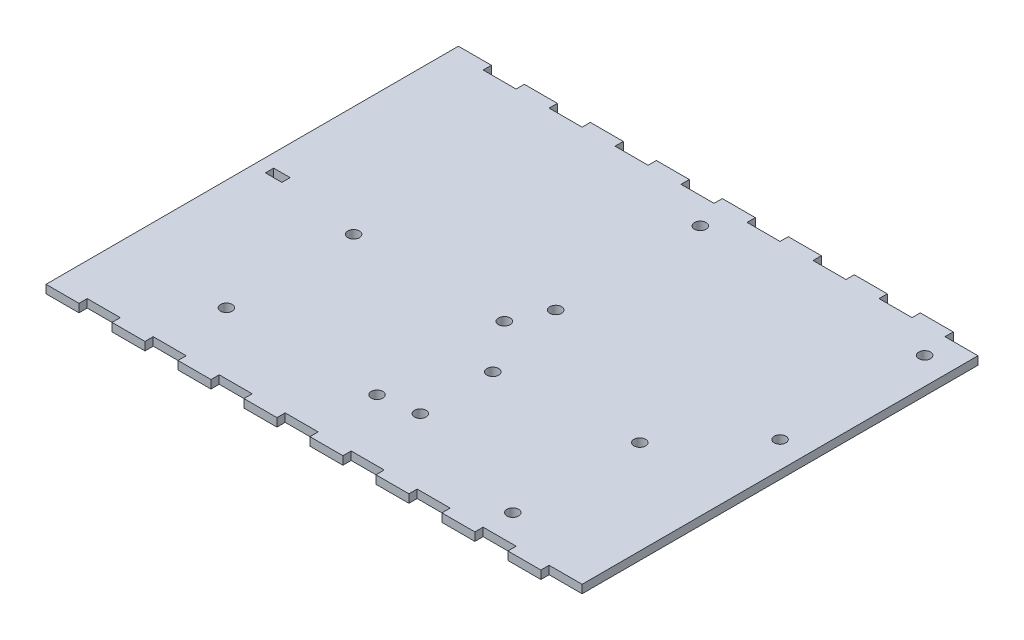
from build123d import *

# Parameters (mm, degrees)
SKETCH1_W               = 203.2
SKETCH1_H               = 152.4
BOSS_EXTRUDE1_DEPTH     = 3.175
SKETCH2_W               = 12.7
SKETCH2_H               = 3.175
BOSS_EXTRUDE2_DEPTH     = 3.175
BOSS_EXTRUDE2_2_DEPTH   = 3.175
BOSS_EXTRUDE2_3_DEPTH   = 3.175
BOSS_EXTRUDE2_4_DEPTH   = 3.175
BOSS_EXTRUDE2_5_DEPTH   = 3.175
BOSS_EXTRUDE2_6_DEPTH   = 3.175
BOSS_EXTRUDE2_7_DEPTH   = 3.175
BOSS_EXTRUDE2_8_DEPTH   = 3.175
BOSS_EXTRUDE2_9_DEPTH   = 3.175
BOSS_EXTRUDE2_10_DEPTH  = 3.175
BOSS_EXTRUDE2_11_DEPTH  = 3.175
BOSS_EXTRUDE2_12_DEPTH  = 3.175
BOSS_EXTRUDE2_13_DEPTH  = 3.175
BOSS_EXTRUDE2_14_DEPTH  = 3.175
BOSS_EXTRUDE2_15_DEPTH  = 3.175
BOSS_EXTRUDE2_16_DEPTH  = 3.175
SKETCH4_R               = 2.249999945
CUT_EXTRUDE1_DEPTH      = 239.445094336
SKETCH5_R               = 2.249999945
CUT_EXTRUDE2_DEPTH      = 411.418751092
CUT_EXTRUDE3_DEPTH      = 181.542007906
CUT_EXTRUDE3_DEPTH_BACK = 181.542007906
SKETCH10_R              = 2.249999945
SKETCH11_W              = 6.35
SKETCH11_H              = 3.175
CUT_EXTRUDE4_DEPTH      = 256.93729945


with BuildPart() as part:
    # Sketch1 → Boss-Extrude1 (new body)
    with BuildSketch(Plane(origin=(0, 0, 0), x_dir=(1, 0, 0), z_dir=(0, 1, 0))):
        with Locations((101.6, 76.2)):
            Rectangle(SKETCH1_W, SKETCH1_H)
    extrude(amount=BOSS_EXTRUDE1_DEPTH)

    # Sketch4 → Cut-Extrude1 (cut, through all)
    with BuildSketch(Plane(origin=(163.318517222, 3.175, 18.128898402), x_dir=(-1, 0, 0), z_dir=(0, 1, 0))):
        with Locations((62.768517222, -41.828898402)):
            Circle(SKETCH4_R)
        with Locations((62.768517222, -90.828898402)):
            Circle(SKETCH4_R)
        with Locations((120.768517222, -90.828898402)):
            Circle(SKETCH4_R)
        with Locations((120.768517222, -41.828898402)):
            Circle(SKETCH4_R)
    extrude(amount=-CUT_EXTRUDE1_DEPTH, mode=Mode.SUBTRACT)

    # Sketch5 → Cut-Extrude2 (cut, through all)
    with BuildSketch(Plane(origin=(307.482010873, 3.175, -268.648993813), x_dir=(-1, 0, 0), z_dir=(0, 1, 0))):
        with Locations((140.407118473, 210.304081528)):
            Circle(SKETCH5_R)
        with Locations((141.507118473, 258.104081528)):
            Circle(SKETCH5_R)
        with Locations((192.307118473, 215.004081528)):
            Circle(SKETCH5_R)
        with Locations((192.307118473, 242.904081528)):
            Circle(SKETCH5_R)
    extrude(amount=-CUT_EXTRUDE2_DEPTH, mode=Mode.SUBTRACT)

    # Sketch10 → Cut-Extrude3 (cut, two sides: drawn at the far end of the back side and taken through both)
    with BuildSketch(Plane(origin=(154.738240667, 3.175, -89.784200023), x_dir=(0, 0, -1), z_dir=(0, 1, 0)).offset(-CUT_EXTRUDE3_DEPTH_BACK)):
        with Locations((-3.423776116, 48.068240667)):
            Circle(SKETCH10_R)
        with Locations((52.455799977, 48.285900219)):
            Circle(SKETCH10_R)
        with Locations((-3.423776116, -38.291759333)):
            Circle(SKETCH10_R)
        with Locations((52.455799977, -38.074099781)):
            Circle(SKETCH10_R)
    extrude(amount=CUT_EXTRUDE3_DEPTH + CUT_EXTRUDE3_DEPTH_BACK, mode=Mode.SUBTRACT)


with BuildPart() as body_2:
    # Sketch2 → Boss-Extrude2 (new body)
    with BuildSketch(Plane(origin=(0, 3.175, 0), x_dir=(1, 0, 0), z_dir=(0, 1, 0))):
        with Locations((31.75, -1.5875)):
            Rectangle(SKETCH2_W, SKETCH2_H)
    extrude(amount=-BOSS_EXTRUDE2_DEPTH)


with BuildPart() as body_3:
    # Sketch2 → Boss-Extrude2 2 (new body)
    with BuildSketch(Plane(origin=(0, 3.175, 0), x_dir=(1, 0, 0), z_dir=(0, 1, 0))):
        with Locations((6.35, -1.5875)):
            Rectangle(SKETCH2_W, SKETCH2_H)
    extrude(amount=-BOSS_EXTRUDE2_2_DEPTH)


with BuildPart() as body_4:
    # Sketch2 → Boss-Extrude2 3 (new body)
    with BuildSketch(Plane(origin=(0, 3.175, 0), x_dir=(1, 0, 0), z_dir=(0, 1, 0))):
        with Locations((57.15, -1.5875)):
            Rectangle(SKETCH2_W, SKETCH2_H)
    extrude(amount=-BOSS_EXTRUDE2_3_DEPTH)


with BuildPart() as body_5:
    # Sketch2 → Boss-Extrude2 4 (new body)
    with BuildSketch(Plane(origin=(0, 3.175, 0), x_dir=(1, 0, 0), z_dir=(0, 1, 0))):
        with Locations((82.55, -1.5875)):
            Rectangle(SKETCH2_W, SKETCH2_H)
    extrude(amount=-BOSS_EXTRUDE2_4_DEPTH)


with BuildPart() as body_6:
    # Sketch2 → Boss-Extrude2 5 (new body)
    with BuildSketch(Plane(origin=(0, 3.175, 0), x_dir=(1, 0, 0), z_dir=(0, 1, 0))):
        with Locations((107.95, -1.5875)):
            Rectangle(SKETCH2_W, SKETCH2_H)
    extrude(amount=-BOSS_EXTRUDE2_5_DEPTH)


with BuildPart() as body_7:
    # Sketch2 → Boss-Extrude2 6 (new body)
    with BuildSketch(Plane(origin=(0, 3.175, 0), x_dir=(1, 0, 0), z_dir=(0, 1, 0))):
        with Locations((133.35, -1.5875)):
            Rectangle(SKETCH2_W, SKETCH2_H)
    extrude(amount=-BOSS_EXTRUDE2_6_DEPTH)


with BuildPart() as body_8:
    # Sketch2 → Boss-Extrude2 7 (new body)
    with BuildSketch(Plane(origin=(0, 3.175, 0), x_dir=(1, 0, 0), z_dir=(0, 1, 0))):
        with Locations((158.75, -1.5875)):
            Rectangle(SKETCH2_W, SKETCH2_H)
    extrude(amount=-BOSS_EXTRUDE2_7_DEPTH)


with BuildPart() as body_9:
    # Sketch2 → Boss-Extrude2 8 (new body)
    with BuildSketch(Plane(origin=(0, 3.175, 0), x_dir=(1, 0, 0), z_dir=(0, 1, 0))):
        with Locations((184.15, -1.5875)):
            Rectangle(SKETCH2_W, SKETCH2_H)
    extrude(amount=-BOSS_EXTRUDE2_8_DEPTH)


with BuildPart() as body_10:
    # Sketch2 → Boss-Extrude2 9 (new body)
    with BuildSketch(Plane(origin=(0, 3.175, 0), x_dir=(1, 0, 0), z_dir=(0, 1, 0))):
        with Locations((184.15, 153.9875)):
            Rectangle(SKETCH2_W, SKETCH2_H)
    extrude(amount=-BOSS_EXTRUDE2_9_DEPTH)


with BuildPart() as body_11:
    # Sketch2 → Boss-Extrude2 10 (new body)
    with BuildSketch(Plane(origin=(0, 3.175, 0), x_dir=(1, 0, 0), z_dir=(0, 1, 0))):
        with Locations((158.75, 153.9875)):
            Rectangle(SKETCH2_W, SKETCH2_H)
    extrude(amount=-BOSS_EXTRUDE2_10_DEPTH)


with BuildPart() as body_12:
    # Sketch2 → Boss-Extrude2 11 (new body)
    with BuildSketch(Plane(origin=(0, 3.175, 0), x_dir=(1, 0, 0), z_dir=(0, 1, 0))):
        with Locations((133.35, 153.9875)):
            Rectangle(SKETCH2_W, SKETCH2_H)
    extrude(amount=-BOSS_EXTRUDE2_11_DEPTH)


with BuildPart() as body_13:
    # Sketch2 → Boss-Extrude2 12 (new body)
    with BuildSketch(Plane(origin=(0, 3.175, 0), x_dir=(1, 0, 0), z_dir=(0, 1, 0))):
        with Locations((107.95, 153.9875)):
            Rectangle(SKETCH2_W, SKETCH2_H)
    extrude(amount=-BOSS_EXTRUDE2_12_DEPTH)


with BuildPart() as body_14:
    # Sketch2 → Boss-Extrude2 13 (new body)
    with BuildSketch(Plane(origin=(0, 3.175, 0), x_dir=(1, 0, 0), z_dir=(0, 1, 0))):
        with Locations((82.55, 153.9875)):
            Rectangle(SKETCH2_W, SKETCH2_H)
    extrude(amount=-BOSS_EXTRUDE2_13_DEPTH)


with BuildPart() as body_15:
    # Sketch2 → Boss-Extrude2 14 (new body)
    with BuildSketch(Plane(origin=(0, 3.175, 0), x_dir=(1, 0, 0), z_dir=(0, 1, 0))):
        with Locations((57.15, 153.9875)):
            Rectangle(SKETCH2_W, SKETCH2_H)
    extrude(amount=-BOSS_EXTRUDE2_14_DEPTH)


with BuildPart() as body_16:
    # Sketch2 → Boss-Extrude2 15 (new body)
    with BuildSketch(Plane(origin=(0, 3.175, 0), x_dir=(1, 0, 0), z_dir=(0, 1, 0))):
        with Locations((31.75, 153.9875)):
            Rectangle(SKETCH2_W, SKETCH2_H)
    extrude(amount=-BOSS_EXTRUDE2_15_DEPTH)


with BuildPart() as body_17:
    # Sketch2 → Boss-Extrude2 16 (new body)
    with BuildSketch(Plane(origin=(0, 3.175, 0), x_dir=(1, 0, 0), z_dir=(0, 1, 0))):
        with Locations((6.35, 153.9875)):
            Rectangle(SKETCH2_W, SKETCH2_H)
    extrude(amount=-BOSS_EXTRUDE2_16_DEPTH)


with BuildPart() as body_3_1:
    add(body_3.part)

    # Combine1: union body 4, body 6, body 8, body 10, body 12, body 14, body 16, body 17, part, body 2, body 5, body 7, body 9, body 11, body 13, body 15
    add(body_4.part)
    add(body_6.part)
    add(body_8.part)
    add(body_10.part)
    add(body_12.part)
    add(body_14.part)
    add(body_16.part)
    add(body_17.part)
    add(part.part)
    add(body_2.part)
    add(body_5.part)
    add(body_7.part)
    add(body_9.part)
    add(body_11.part)
    add(body_13.part)
    add(body_15.part)

    # Sketch11 → Cut-Extrude4 (cut, through all)
    with BuildSketch(Plane(origin=(0, 3.175, 0), x_dir=(1, 0, 0), z_dir=(0, 1, 0))):
        with Locations((8.255, 77.7875)):
            Rectangle(SKETCH11_W, SKETCH11_H)
    extrude(amount=-CUT_EXTRUDE4_DEPTH, mode=Mode.SUBTRACT)


solid = body_3_1.part
